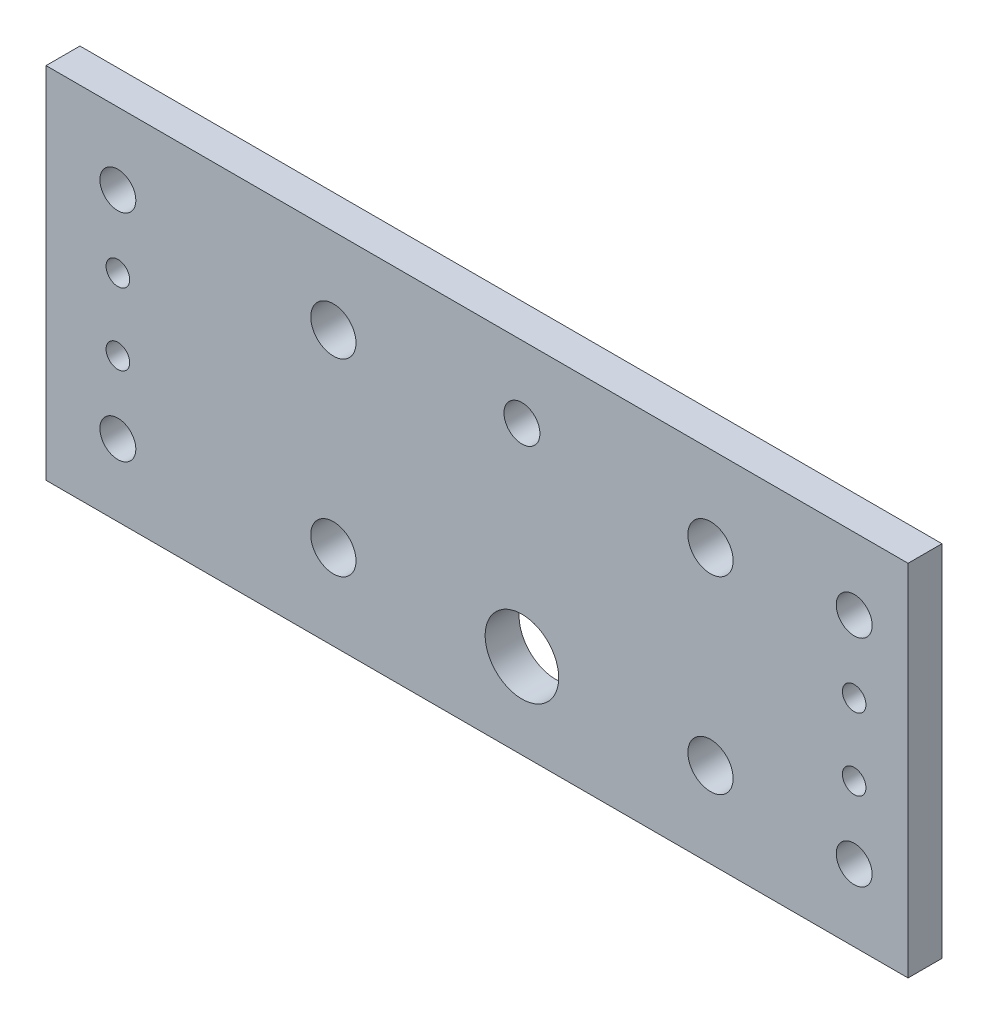
from build123d import *

# Parameters (mm, degrees)
SKETCH1_W           = 152.4
SKETCH1_H           = 63.5
SKETCH1_R           = 6.5
SKETCH1_R_2         = 2.0828
SKETCH1_R_3         = 4
SKETCH1_R_4         = 3.175
BOSS_EXTRUDE1_DEPTH = 5.9944


with BuildPart() as part:
    # Sketch1 → Boss-Extrude1 (new body)
    with BuildSketch(Plane.XY):
        with Locations((76.2, 31.75)):
            Rectangle(SKETCH1_W, SKETCH1_H)
        with Locations((84.1375, 15.0749)):
            Circle(SKETCH1_R, mode=Mode.SUBTRACT)
        with Locations((12.7, 38.1)):
            Circle(SKETCH1_R_2, mode=Mode.SUBTRACT)
        with Locations((12.7, 25.4)):
            Circle(SKETCH1_R_2, mode=Mode.SUBTRACT)
        with Locations((142.875, 38.1)):
            Circle(SKETCH1_R_2, mode=Mode.SUBTRACT)
        with Locations((142.875, 25.4)):
            Circle(SKETCH1_R_2, mode=Mode.SUBTRACT)
        with Locations((50.8, 48.4251)):
            Circle(SKETCH1_R_3, mode=Mode.SUBTRACT)
        with Locations((12.7, 50.8)):
            Circle(SKETCH1_R_4, mode=Mode.SUBTRACT)
        with Locations((12.7, 12.7)):
            Circle(SKETCH1_R_4, mode=Mode.SUBTRACT)
        with Locations((117.475, 48.4251)):
            Circle(SKETCH1_R_3, mode=Mode.SUBTRACT)
        with Locations((117.475, 15.0749)):
            Circle(SKETCH1_R_3, mode=Mode.SUBTRACT)
        with Locations((50.8, 15.0749)):
            Circle(SKETCH1_R_3, mode=Mode.SUBTRACT)
        with Locations((142.875, 50.8)):
            Circle(SKETCH1_R_4, mode=Mode.SUBTRACT)
        with Locations((142.875, 12.7)):
            Circle(SKETCH1_R_4, mode=Mode.SUBTRACT)
        with Locations((84.1375, 50.8)):
            Circle(SKETCH1_R_4, mode=Mode.SUBTRACT)
    extrude(amount=BOSS_EXTRUDE1_DEPTH)


solid = part.part
